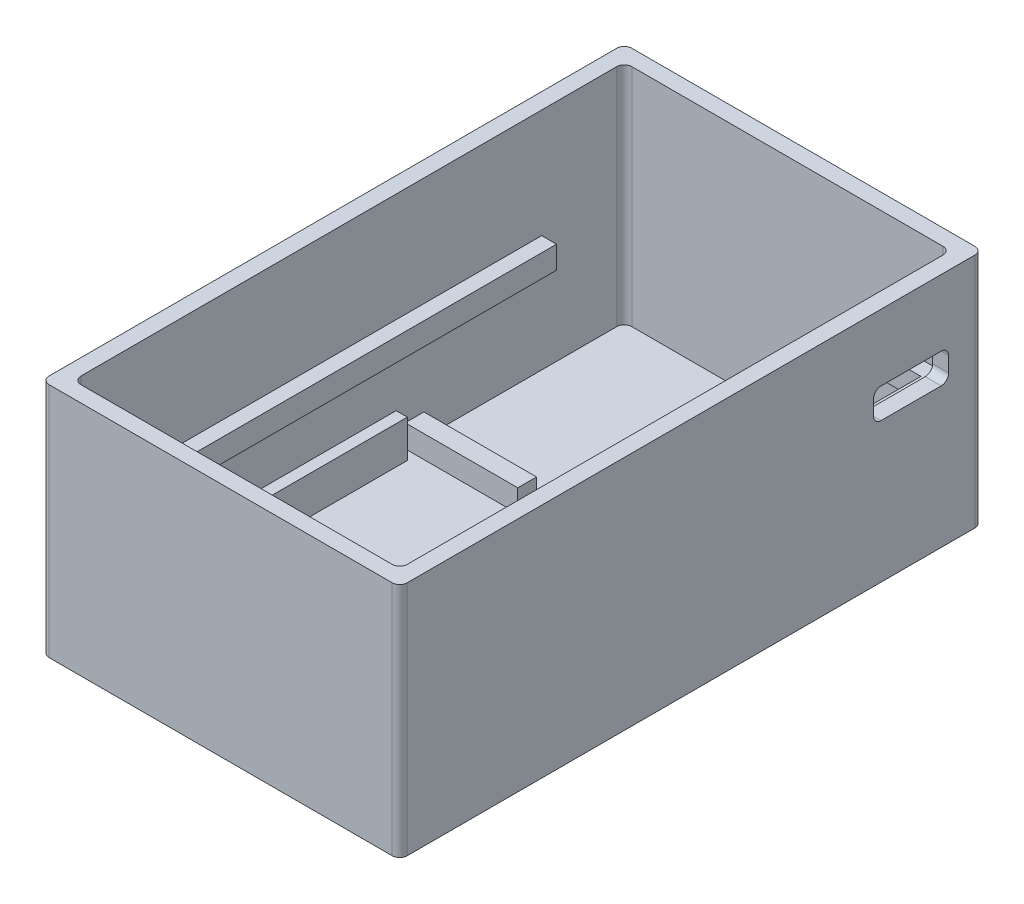
from build123d import *

# Parameters (mm, degrees)
PCB_DIMENSIONS_W    = 47.716732244
PCB_DIMENSIONS_H    = 77.636732244
BOSS_EXTRUDE3_DEPTH = 1.5
SKETCH5_W           = 47.716732244
SKETCH5_H           = 77.636732244
SKETCH5_W_2         = 43.474091557
SKETCH5_H_2         = 73.394091557
BOSS_EXTRUDE5_DEPTH = 30
FILLET1_R           = 1
SKETCH9_W           = 1.93805105
SKETCH9_H           = 42
SKETCH9_W_2         = 1.938051049
BOSS_EXTRUDE6_DEPTH = 5
SKETCH14_W          = 15
SKETCH14_H          = 2.5
BOSS_EXTRUDE7_DEPTH = 3
SKETCH15_W          = 75.636732244
SKETCH15_H          = 3
BOSS_EXTRUDE8_DEPTH = 46
SKETCH17_W          = 39.522771214
SKETCH17_H          = 62.982276128
CUT_EXTRUDE1_DEPTH  = 3
CUT_EXTRUDE2_DEPTH  = 3
SKETCH19_W          = 10
SKETCH19_H          = 4
CUT_EXTRUDE3_DEPTH  = 10
FILLET2_R           = 1
SCALE1_SCALE        = 0.99


with BuildPart() as part:
    # PCB Dimensions → Boss-Extrude3 (new body)
    with BuildSketch(Plane(origin=(0, 0, 0), x_dir=(1, 0, 0), z_dir=(0, 1, 0))):
        with Locations((20.322832216, -35.282832216)):
            Rectangle(PCB_DIMENSIONS_W, PCB_DIMENSIONS_H)
    extrude(amount=BOSS_EXTRUDE3_DEPTH)

    # Sketch5 → Boss-Extrude5 (add)
    with BuildSketch(Plane(origin=(0, 1.5, 0), x_dir=(1, 0, 0), z_dir=(0, 1, 0))):
        with Locations((20.322832216, -35.282832216)):
            Rectangle(SKETCH5_W, SKETCH5_H)
        with Locations((20.322832217, -35.282832217)):
            Rectangle(SKETCH5_W_2, SKETCH5_H_2, mode=Mode.SUBTRACT)
    extrude(amount=BOSS_EXTRUDE5_DEPTH)

    # Fillet1
    fillet1_edges = [part.edges().sort_by_distance(p)[0] for p in [
        (42.059877995, 16.5, -1.414213562),
        (-1.414213562, 16.5, -1.414213562),
        (-1.414213562, 16.5, 71.979877995),
        (42.059877995, 16.5, 71.979877995),
        (44.181198338, 15.75, 74.101198338),
        (-3.535533906, 15.75, 74.101198338),
        (-3.535533906, 15.75, -3.535533906),
        (44.181198338, 15.75, -3.535533906),
    ]]
    fillet(fillet1_edges, radius=FILLET1_R)

    # Sketch9 → Boss-Extrude6 (add)
    with BuildSketch(Plane(origin=(0, 1.5, 0), x_dir=(1, 0, 0), z_dir=(0, 1, 0))):
        with Locations((-0.88911969, -49.979881394)):
            Rectangle(SKETCH9_W, SKETCH9_H)
        with Locations((41.534784122, -49.979881394)):
            Rectangle(SKETCH9_W_2, SKETCH9_H)
    extrude(amount=BOSS_EXTRUDE6_DEPTH)

    # Sketch14 → Boss-Extrude7 (add)
    with BuildSketch(Plane(origin=(0, 1.5, 0), x_dir=(1, 0, 0), z_dir=(0, 1, 0))):
        with Locations((6.085786438, -26.529881394)):
            Rectangle(SKETCH14_W, SKETCH14_H)
        with Locations((34.559877995, -26.529881394)):
            Rectangle(SKETCH14_W, SKETCH14_H)
    extrude(amount=BOSS_EXTRUDE7_DEPTH)

    # Sketch15 → Boss-Extrude8 (add)
    with BuildSketch(Plane(origin=(44.181198338, 0, 0), x_dir=(0, 0, -1), z_dir=(1, 0, 0))):
        with Locations((-35.282832216, 15.5)):
            Rectangle(SKETCH15_W, SKETCH15_H)
    extrude(amount=-BOSS_EXTRUDE8_DEPTH)

    # Sketch17 → Cut-Extrude1 (cut)
    with BuildSketch(Plane(origin=(0, 17, 0), x_dir=(1, 0, 0), z_dir=(0, 1, 0))):
        with Locations((20.322832216, -32.052584673)):
            Rectangle(SKETCH17_W, SKETCH17_H)
    extrude(amount=-CUT_EXTRUDE1_DEPTH, mode=Mode.SUBTRACT)

    # Sketch18 → Cut-Extrude2 (cut)
    with BuildSketch(Plane(origin=(0, 17, 0), x_dir=(1, 0, 0), z_dir=(0, 1, 0))):
        with BuildLine():
            Line((-1.414213562, -9.585786438), (28.585786438, -9.585786438))
            Line((28.585786438, -9.585786438), (28.585786438, 1.414213562))
            Line((28.585786438, 1.414213562), (-0.414213562, 1.414213562))
            ThreePointArc((-0.414213562, 1.414213562), (-1.121320344, 1.121320344), (-1.414213562, 0.414213562))
            Line((-1.414213562, 0.414213562), (-1.414213562, -9.585786438))
        make_face()
    extrude(amount=-CUT_EXTRUDE2_DEPTH, mode=Mode.SUBTRACT)

    # Sketch19 → Cut-Extrude3 (cut)
    with BuildSketch(Plane(origin=(44.181198338, 0, 0), x_dir=(0, 0, -1), z_dir=(1, 0, 0))):
        with Locations((-5.964466094, 20.65)):
            Rectangle(SKETCH19_W, SKETCH19_H)
    extrude(amount=-CUT_EXTRUDE3_DEPTH, mode=Mode.SUBTRACT)

    # Fillet2
    fillet2_edges = [part.edges().sort_by_distance(p)[0] for p in [
        (43.120538167, 22.65, 0.964466094),
        (43.120538167, 18.65, 0.964466094),
        (43.120538167, 18.65, 10.964466094),
        (43.120538167, 22.65, 10.964466094),
    ]]
    fillet(fillet2_edges, radius=FILLET2_R)


with BuildPart() as part_1:
    # Scale1: scaled about (20.339813051, 12.239416384, 37.051144502)
    add(part.part.scale(SCALE1_SCALE).moved(Location((0.203398131, 0.122394164, 0.370511445))))


solid = part_1.part
